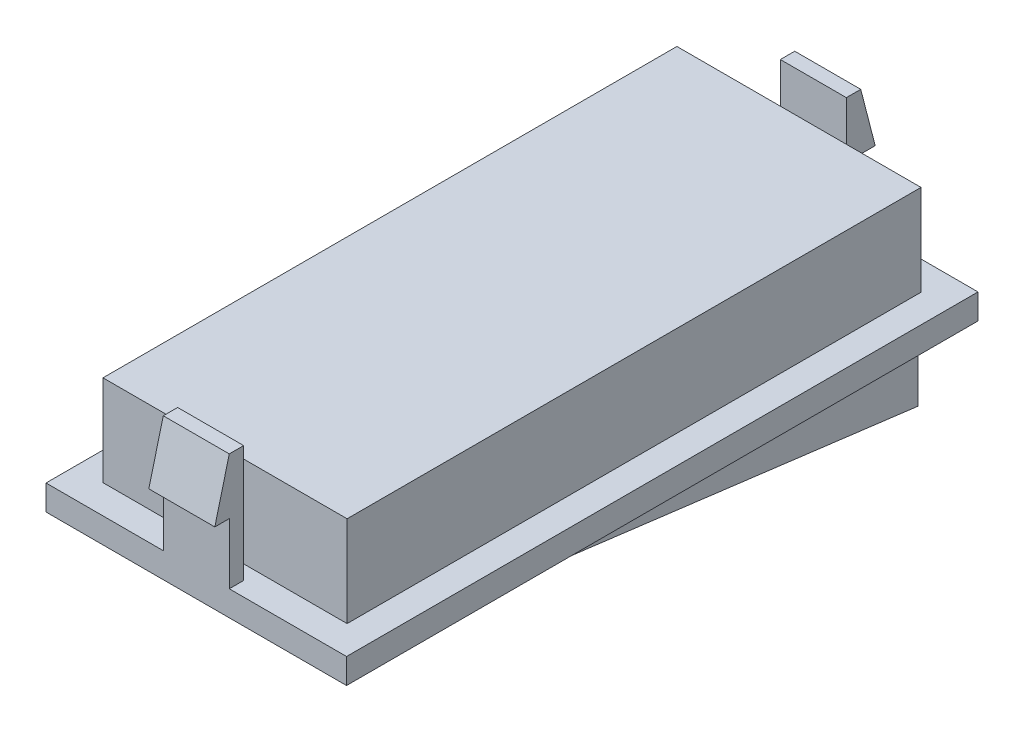
from build123d import *

# Parameters (mm, degrees)
SKETCH1_W           = 24.13
SKETCH1_H           = 50.7
BOSS_EXTRUDE1_DEPTH = 2.02
SKETCH2_W           = 19.6
SKETCH2_H           = 46.08
BOSS_EXTRUDE2_DEPTH = 7.29
BOSS_EXTRUDE3_START = -2.265
BOSS_EXTRUDE3_DEPTH = 19.6
SKETCH4_W           = 5.3
SKETCH4_H           = 9.38
BOSS_EXTRUDE4_DEPTH = 1.155
BOSS_EXTRUDE5_DEPTH = 5.3


with BuildPart() as part:
    # Sketch1 → Boss-Extrude1 (new body)
    with BuildSketch(Plane(origin=(0, 0, 0), x_dir=(1, 0, 0), z_dir=(0, 1, 0))):
        Rectangle(SKETCH1_W, SKETCH1_H)
    extrude(amount=BOSS_EXTRUDE1_DEPTH)

    # Sketch2 → Boss-Extrude2 (add)
    with BuildSketch(Plane(origin=(0, 2.02, 0), x_dir=(1, 0, 0), z_dir=(0, 1, 0))):
        Rectangle(SKETCH2_W, SKETCH2_H)
    extrude(amount=BOSS_EXTRUDE2_DEPTH)

    # Sketch3 → Boss-Extrude3 (add)
    with BuildSketch(Plane(origin=(12.065, 0, 0), x_dir=(0, 0, -1), z_dir=(1, 0, 0)).offset(BOSS_EXTRUDE3_START)):
        Polygon((-22.884943392, 0), (22.781251072, -5.781035599), (22.781251072, 0), align=None)
    extrude(amount=-BOSS_EXTRUDE3_DEPTH)

    # Sketch4 → Boss-Extrude4 (add)
    with BuildSketch(Plane(origin=(0, 0, -25.35), x_dir=(-1, 0, 0), z_dir=(0, 0, -1))):
        with Locations((0, 6.71)):
            Rectangle(SKETCH4_W, SKETCH4_H)
    boss_extrude4 = extrude(amount=-BOSS_EXTRUDE4_DEPTH)

    # Sketch5 → Boss-Extrude5 (add)
    with BuildSketch(Plane(origin=(2.65, 0, 0), x_dir=(0, 0, -1), z_dir=(1, 0, 0))):
        Polygon((25.35, 11.4), (25.35, 6.9), (26.51, 6.9), align=None)
    boss_extrude5 = extrude(amount=-BOSS_EXTRUDE5_DEPTH)

    # Mirror1: Boss-Extrude4, Boss-Extrude5 across plane
    add(boss_extrude4.mirror(Plane.XY))
    add(boss_extrude5.mirror(Plane.XY))


solid = part.part
